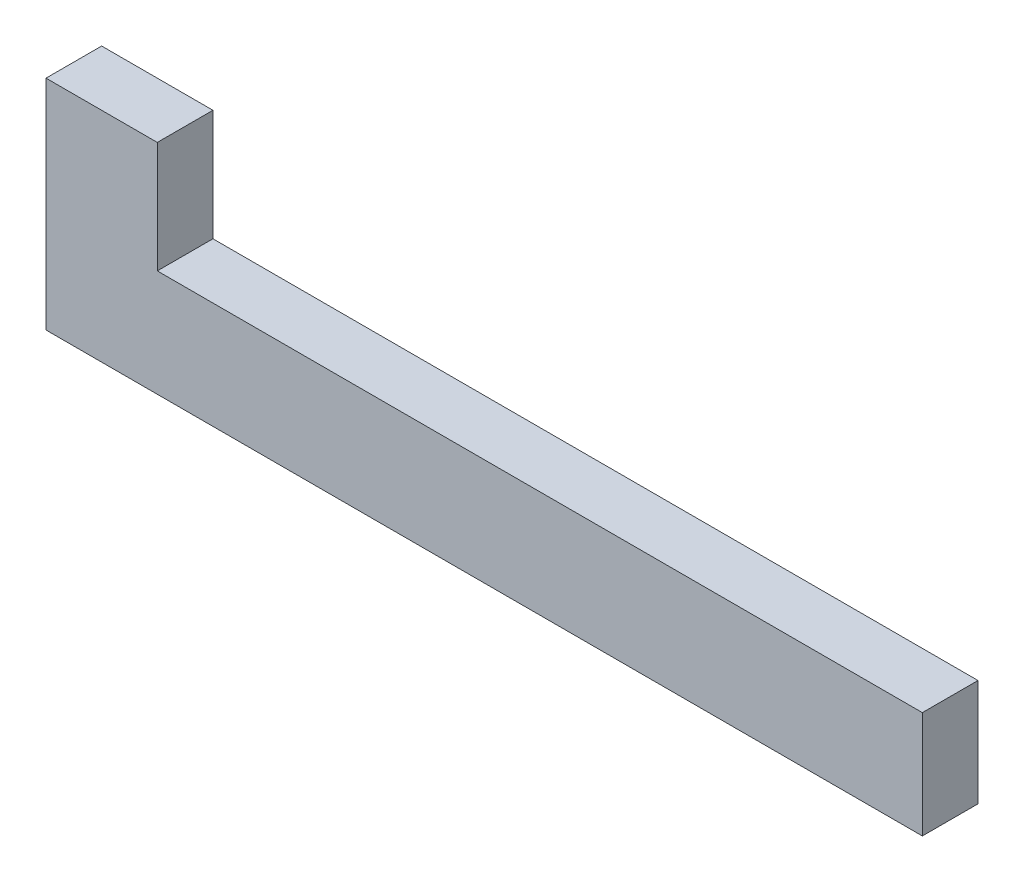
from build123d import *

# Parameters (mm, degrees)
SKETCH1_W           = 50
SKETCH1_H           = 3.175
BOSS_EXTRUDE1_DEPTH = 6.096
SKETCH2_W           = 6.35
SKETCH2_H           = 6.35
BOSS_EXTRUDE2_DEPTH = 3.175


with BuildPart() as part:
    # Sketch1 → Boss-Extrude1 (new body)
    with BuildSketch(Plane(origin=(0, 0, 0), x_dir=(1, 0, 0), z_dir=(0, 1, 0))):
        Rectangle(SKETCH1_W, SKETCH1_H)
    extrude(amount=BOSS_EXTRUDE1_DEPTH)

    # Sketch2 → Boss-Extrude2 (add)
    with BuildSketch(Plane(origin=(0, 0, -1.5875), x_dir=(-1, 0, 0), z_dir=(0, 0, -1))):
        with Locations((21.825, 9.271)):
            Rectangle(SKETCH2_W, SKETCH2_H)
    extrude(amount=-BOSS_EXTRUDE2_DEPTH)


solid = part.part
